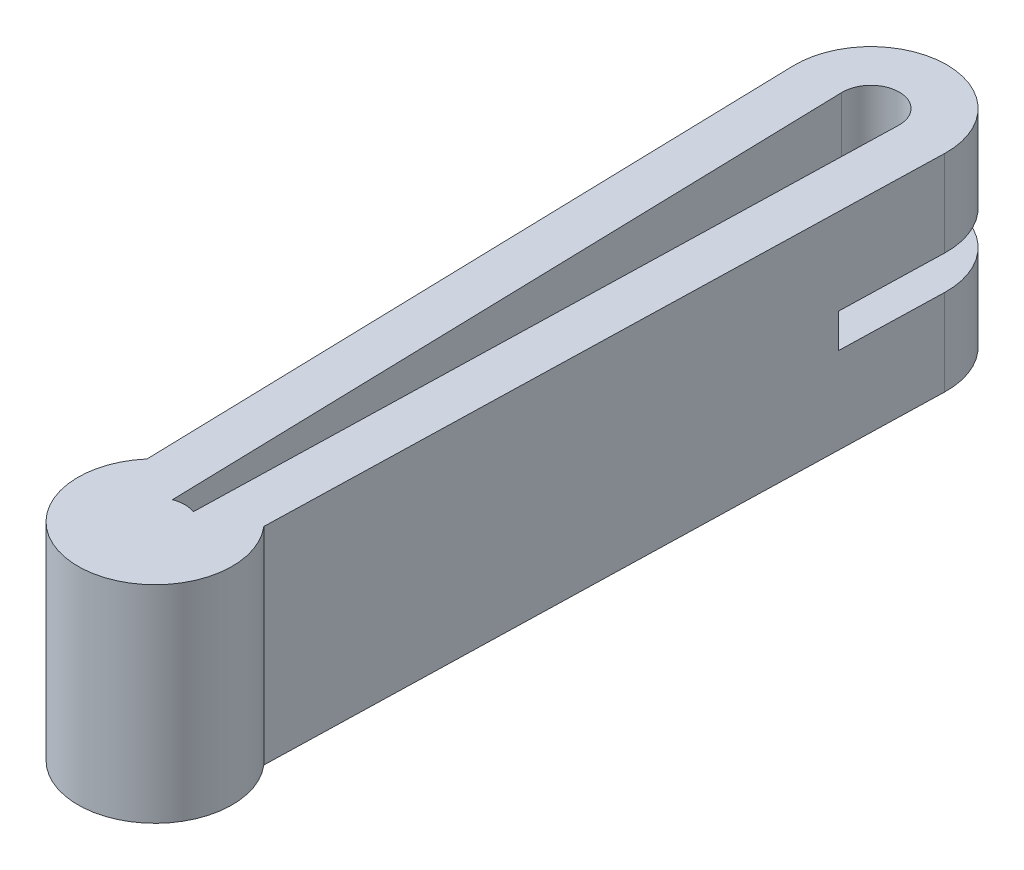
from build123d import *

# Parameters (mm, degrees)
BOSS_EXTRUDE1_DEPTH = 27.686
SKETCH2_W           = 29.921903197
SKETCH2_H           = 4.572
CUT_EXTRUDE1_DEPTH  = 13.843
SKETCH3_OUTSIDE_W   = 46.952
SKETCH3_OUTSIDE_H   = 142.689
CUT_EXTRUDE2_DEPTH  = 27.686


with BuildPart() as part:
    # Sketch1 → Boss-Extrude1 (new body)
    with BuildSketch(Plane(origin=(0, 0, 0), x_dir=(1, 0, 0), z_dir=(0, 1, 0))):
        with BuildLine():
            Line((-10.156518422, -0.265957795), (-7.828589994, -89.165957795))
            ThreePointArc((-7.828589994, -89.165957795), (0, -106.245464925), (7.828589994, -89.165957795))
            Line((7.828589994, -89.165957795), (10.156518422, -0.265957795))
            ThreePointArc((10.156518422, -0.265957795), (0, 10.16), (-10.156518422, -0.265957795))
        make_face()
    extrude(amount=BOSS_EXTRUDE1_DEPTH)

    # Sketch2 → Cut-Extrude1 (cut, symmetric)
    with BuildSketch(Plane(origin=(0, 0, 0.265957795), x_dir=(-1, 0, 0), z_dir=(0, 0, -1))):
        with Locations((1.107435291, 13.843)):
            Rectangle(SKETCH2_W, SKETCH2_H)
    extrude(amount=CUT_EXTRUDE1_DEPTH, both=True, mode=Mode.SUBTRACT)

    # Sketch3 outside → Cut-Extrude2 (cut)
    with BuildSketch(Plane.XZ):
        with Locations((0, 48.0425)):
            Rectangle(SKETCH3_OUTSIDE_W, SKETCH3_OUTSIDE_H)
        with BuildLine():
            Line((10.156518422, 0.265957795), (7.828589994, 89.165957795))
            ThreePointArc((7.828589994, 89.165957795), (0, 106.245464925), (-7.828589994, 89.165957795))
            Line((-7.828589994, 89.165957795), (-10.156518422, 0.265957795))
            ThreePointArc((-10.156518422, 0.265957795), (0, -10.16), (10.156518422, 0.265957795))
        make_face(mode=Mode.SUBTRACT)
        with BuildLine():
            Line((-1.397467487, 92.180775304), (-3.808694408, 0.099734173))
            ThreePointArc((-3.808694408, 0.099734173), (0, -3.81), (3.808694408, 0.099734173))
            Line((3.808694408, 0.099734173), (1.397467487, 92.180775304))
            ThreePointArc((1.397467487, 92.180775304), (0, 91.927632861), (-1.397467487, 92.180775304))
        make_face()
    extrude(amount=-CUT_EXTRUDE2_DEPTH, mode=Mode.SUBTRACT)


solid = part.part
